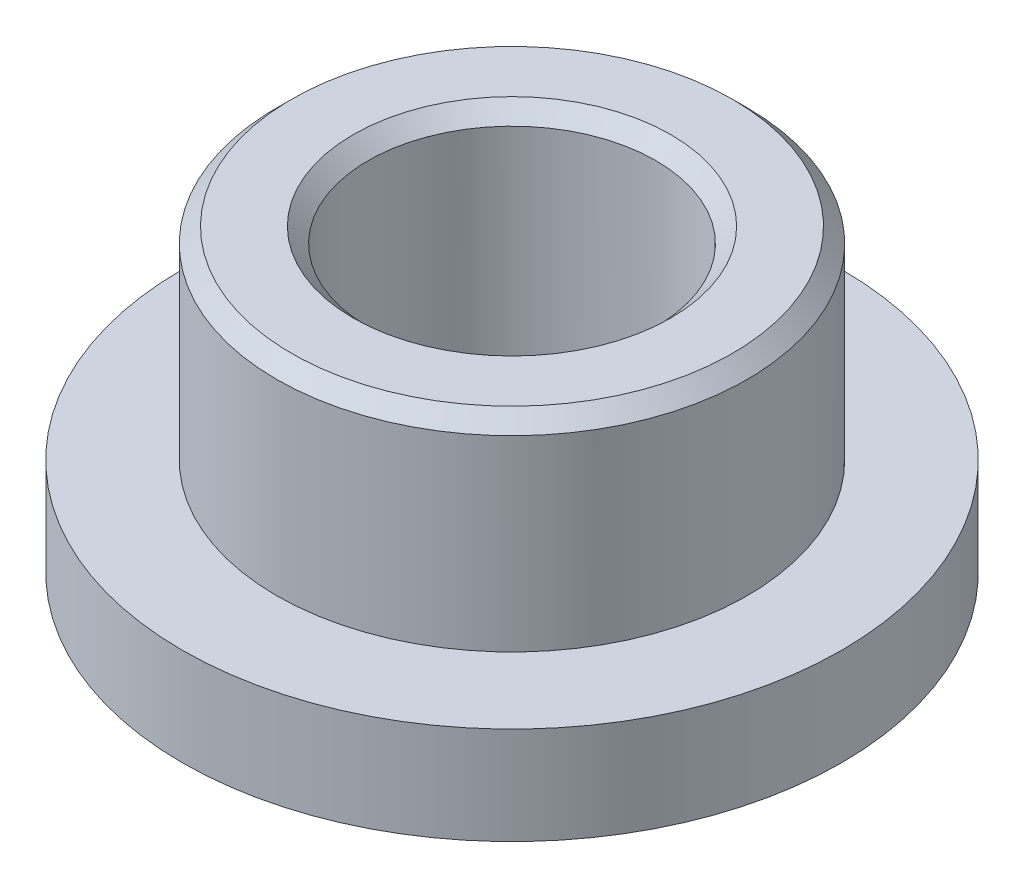
from build123d import *

# Parameters (mm, degrees)
CUT_EXTRUDE1_DEPTH      = 15.637622758
CUT_EXTRUDE1_DEPTH_BACK = 15.637622758
SKETCH2_W               = 14
SKETCH2_H               = 8
CHAMFER1_SIZE           = 0.25


with BuildPart() as part:
    # Sketch1 → Revolve1 (revolve)
    with BuildSketch(Plane.XY):
        Polygon((3.925, 1.6256), (3.925, 12.4), (2.4, 12.4), (2.4, 0.2), (2.6, 0), (5.5, 0), (5.5, 1.6256), align=None)
    revolve(axis=Axis((0, 0, 0), (0, -1, 0)))

    # Sketch2 → Cut-Extrude1 (cut, two sides: drawn at the far end of the back side and taken through both)
    with BuildSketch(Plane.XY.offset(-CUT_EXTRUDE1_DEPTH_BACK)):
        with Locations((0, 9)):
            Rectangle(SKETCH2_W, SKETCH2_H)
    extrude(amount=CUT_EXTRUDE1_DEPTH + CUT_EXTRUDE1_DEPTH_BACK, mode=Mode.SUBTRACT)

    # Chamfer1
    chamfer1_edges = [part.edges().sort_by_distance(p)[0] for p in [
        (-2.4, 5, 0),
        (-3.925, 5, 0),
    ]]
    chamfer(chamfer1_edges, length=CHAMFER1_SIZE)


solid = part.part
